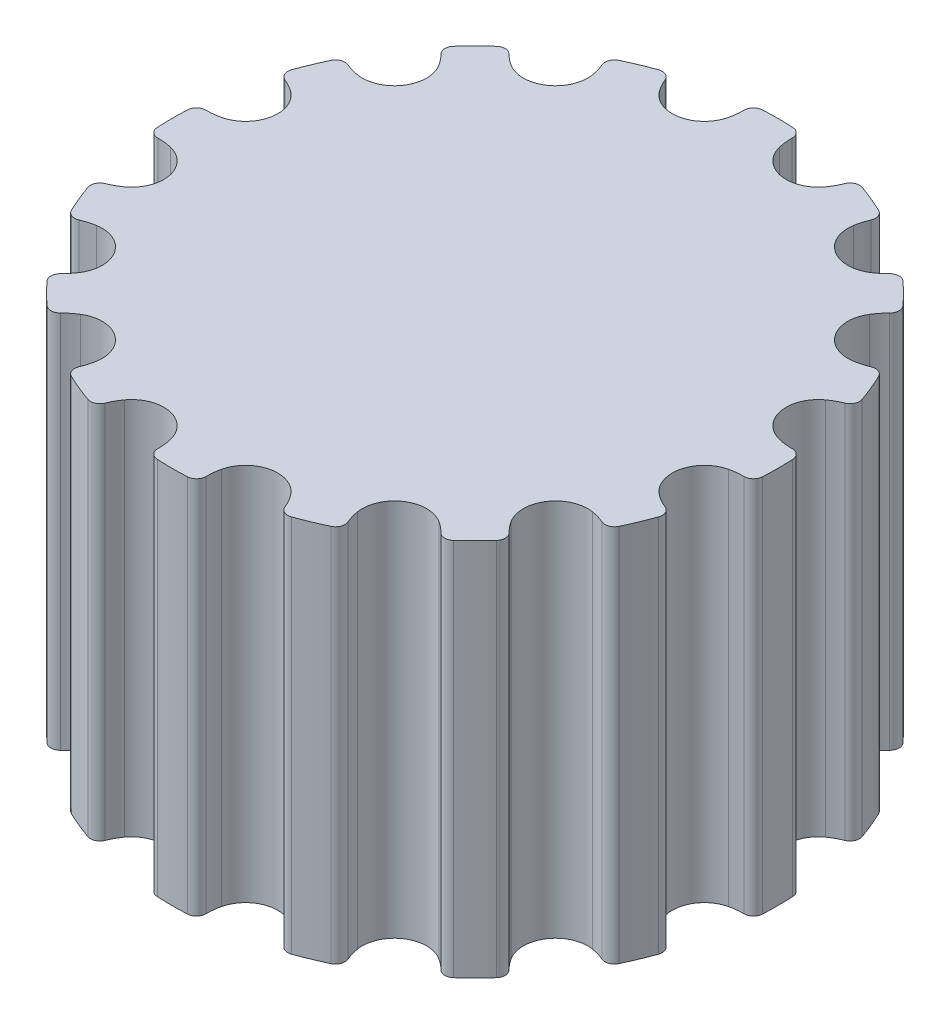
from build123d import *

# Parameters (mm, degrees)
BOSS_EXTRUDE1_DEPTH = 10


with BuildPart() as part:
    # Sketch1 → Boss-Extrude1 (new body)
    with BuildSketch(Plane(origin=(0, 0, 0), x_dir=(1, 0, 0), z_dir=(0, 1, 0))):
        with BuildLine():
            ThreePointArc((-0.399150386, 7.990036231), (0, 8), (0.399150386, 7.990036231))
            ThreePointArc((0.399150386, 7.990036231), (0.569055955, 7.911338515), (0.636650592, 7.736718362))
            ThreePointArc((0.636650592, 7.736718362), (0.645310767, 7.551140962), (0.676545739, 7.368006184))
            ThreePointArc((0.676545739, 7.368006184), (0.913327757, 6.950762578), (1.338319609, 6.728187024))
            ThreePointArc((1.338319609, 6.728187024), (1.816136859, 6.771182682), (2.194567135, 7.066052955))
            ThreePointArc((2.194567135, 7.066052955), (2.293507132, 7.223294321), (2.372525487, 7.391431377))
            ThreePointArc((2.372525487, 7.391431377), (2.501799028, 7.526892015), (2.688887618, 7.534579177))
            ThreePointArc((2.688887618, 7.534579177), (3.061467459, 7.39103626), (3.426421361, 7.229082698))
            ThreePointArc((3.426421361, 7.229082698), (3.553277327, 7.091355443), (3.548902389, 6.90416011))
            ThreePointArc((3.548902389, 6.90416011), (3.485885951, 6.729394842), (3.444660657, 6.548247264))
            ThreePointArc((3.444660657, 6.548247264), (3.503746502, 6.07215188), (3.811211799, 5.70388154))
            ThreePointArc((3.811211799, 5.70388154), (4.269111103, 5.560751604), (4.731577057, 5.688357216))
            ThreePointArc((4.731577057, 5.688357216), (4.88315936, 5.795766599), (5.020506067, 5.920865969))
            ThreePointArc((5.020506067, 5.920865969), (5.191777788, 5.996544437), (5.367566856, 5.932050745))
            ThreePointArc((5.367566856, 5.932050745), (5.656854249, 5.656854249), (5.932050745, 5.367566856))
            ThreePointArc((5.932050745, 5.367566856), (5.996544437, 5.191777788), (5.920865969, 5.020506067))
            ThreePointArc((5.920865969, 5.020506067), (5.795766599, 4.88315936), (5.688357216, 4.731577057))
            ThreePointArc((5.688357216, 4.731577057), (5.560751604, 4.269111103), (5.70388154, 3.811211799))
            ThreePointArc((5.70388154, 3.811211799), (6.07215188, 3.503746502), (6.548247264, 3.444660657))
            ThreePointArc((6.548247264, 3.444660657), (6.729394842, 3.485885951), (6.90416011, 3.548902389))
            ThreePointArc((6.90416011, 3.548902389), (7.091355443, 3.553277327), (7.229082698, 3.426421361))
            ThreePointArc((7.229082698, 3.426421361), (7.39103626, 3.061467459), (7.534579177, 2.688887618))
            ThreePointArc((7.534579177, 2.688887618), (7.526892015, 2.501799028), (7.391431377, 2.372525487))
            ThreePointArc((7.391431377, 2.372525487), (7.223294321, 2.293507132), (7.066052955, 2.194567135))
            ThreePointArc((7.066052955, 2.194567135), (6.771182682, 1.816136859), (6.728187024, 1.338319609))
            ThreePointArc((6.728187024, 1.338319609), (6.950762578, 0.913327757), (7.368006184, 0.676545739))
            ThreePointArc((7.368006184, 0.676545739), (7.551140962, 0.645310767), (7.736718362, 0.636650592))
            ThreePointArc((7.736718362, 0.636650592), (7.911338515, 0.569055955), (7.990036231, 0.399150386))
            ThreePointArc((7.990036231, 0.399150386), (8, 0), (7.990036231, -0.399150386))
            ThreePointArc((7.990036231, -0.399150386), (7.911338515, -0.569055955), (7.736718362, -0.636650592))
            ThreePointArc((7.736718362, -0.636650592), (7.551140962, -0.645310767), (7.368006184, -0.676545739))
            ThreePointArc((7.368006184, -0.676545739), (6.950762578, -0.913327757), (6.728187024, -1.338319609))
            ThreePointArc((6.728187024, -1.338319609), (6.771182682, -1.816136859), (7.066052955, -2.194567135))
            ThreePointArc((7.066052955, -2.194567135), (7.223294321, -2.293507132), (7.391431377, -2.372525487))
            ThreePointArc((7.391431377, -2.372525487), (7.526892015, -2.501799028), (7.534579177, -2.688887618))
            ThreePointArc((7.534579177, -2.688887618), (7.39103626, -3.061467459), (7.229082698, -3.426421361))
            ThreePointArc((7.229082698, -3.426421361), (7.091355443, -3.553277327), (6.90416011, -3.548902389))
            ThreePointArc((6.90416011, -3.548902389), (6.729394842, -3.485885951), (6.548247264, -3.444660657))
            ThreePointArc((6.548247264, -3.444660657), (6.07215188, -3.503746502), (5.70388154, -3.811211799))
            ThreePointArc((5.70388154, -3.811211799), (5.560751604, -4.269111103), (5.688357216, -4.731577057))
            ThreePointArc((5.688357216, -4.731577057), (5.795766599, -4.88315936), (5.920865969, -5.020506067))
            ThreePointArc((5.920865969, -5.020506067), (5.996544437, -5.191777788), (5.932050745, -5.367566856))
            ThreePointArc((5.932050745, -5.367566856), (5.656854249, -5.656854249), (5.367566856, -5.932050745))
            ThreePointArc((5.367566856, -5.932050745), (5.191777788, -5.996544437), (5.020506067, -5.920865969))
            ThreePointArc((5.020506067, -5.920865969), (4.88315936, -5.795766599), (4.731577057, -5.688357216))
            ThreePointArc((4.731577057, -5.688357216), (4.269111103, -5.560751604), (3.811211799, -5.70388154))
            ThreePointArc((3.811211799, -5.70388154), (3.503746502, -6.07215188), (3.444660657, -6.548247264))
            ThreePointArc((3.444660657, -6.548247264), (3.485885951, -6.729394842), (3.548902389, -6.90416011))
            ThreePointArc((3.548902389, -6.90416011), (3.553277327, -7.091355443), (3.426421361, -7.229082698))
            ThreePointArc((3.426421361, -7.229082698), (3.061467459, -7.39103626), (2.688887618, -7.534579177))
            ThreePointArc((2.688887618, -7.534579177), (2.501799028, -7.526892015), (2.372525487, -7.391431377))
            ThreePointArc((2.372525487, -7.391431377), (2.293507132, -7.223294321), (2.194567135, -7.066052955))
            ThreePointArc((2.194567135, -7.066052955), (1.816136859, -6.771182682), (1.338319609, -6.728187024))
            ThreePointArc((1.338319609, -6.728187024), (0.913327757, -6.950762578), (0.676545739, -7.368006184))
            ThreePointArc((0.676545739, -7.368006184), (0.645310767, -7.551140962), (0.636650592, -7.736718362))
            ThreePointArc((0.636650592, -7.736718362), (0.569055955, -7.911338515), (0.399150386, -7.990036231))
            ThreePointArc((0.399150386, -7.990036231), (0, -8), (-0.399150386, -7.990036231))
            ThreePointArc((-0.399150386, -7.990036231), (-0.569055955, -7.911338515), (-0.636650592, -7.736718362))
            ThreePointArc((-0.636650592, -7.736718362), (-0.645310767, -7.551140962), (-0.676545739, -7.368006184))
            ThreePointArc((-0.676545739, -7.368006184), (-0.913327757, -6.950762578), (-1.338319609, -6.728187024))
            ThreePointArc((-1.338319609, -6.728187024), (-1.816136859, -6.771182682), (-2.194567135, -7.066052955))
            ThreePointArc((-2.194567135, -7.066052955), (-2.293507132, -7.223294321), (-2.372525487, -7.391431377))
            ThreePointArc((-2.372525487, -7.391431377), (-2.501799028, -7.526892015), (-2.688887618, -7.534579177))
            ThreePointArc((-2.688887618, -7.534579177), (-3.061467459, -7.39103626), (-3.426421361, -7.229082698))
            ThreePointArc((-3.426421361, -7.229082698), (-3.553277327, -7.091355443), (-3.548902389, -6.90416011))
            ThreePointArc((-3.548902389, -6.90416011), (-3.485885951, -6.729394842), (-3.444660657, -6.548247264))
            ThreePointArc((-3.444660657, -6.548247264), (-3.503746502, -6.07215188), (-3.811211799, -5.70388154))
            ThreePointArc((-3.811211799, -5.70388154), (-4.269111103, -5.560751604), (-4.731577057, -5.688357216))
            ThreePointArc((-4.731577057, -5.688357216), (-4.88315936, -5.795766599), (-5.020506067, -5.920865969))
            ThreePointArc((-5.020506067, -5.920865969), (-5.191777788, -5.996544437), (-5.367566856, -5.932050745))
            ThreePointArc((-5.367566856, -5.932050745), (-5.656854249, -5.656854249), (-5.932050745, -5.367566856))
            ThreePointArc((-5.932050745, -5.367566856), (-5.996544437, -5.191777788), (-5.920865969, -5.020506067))
            ThreePointArc((-5.920865969, -5.020506067), (-5.795766599, -4.88315936), (-5.688357216, -4.731577057))
            ThreePointArc((-5.688357216, -4.731577057), (-5.560751604, -4.269111103), (-5.70388154, -3.811211799))
            ThreePointArc((-5.70388154, -3.811211799), (-6.07215188, -3.503746502), (-6.548247264, -3.444660657))
            ThreePointArc((-6.548247264, -3.444660657), (-6.729394842, -3.485885951), (-6.90416011, -3.548902389))
            ThreePointArc((-6.90416011, -3.548902389), (-7.091355443, -3.553277327), (-7.229082698, -3.426421361))
            ThreePointArc((-7.229082698, -3.426421361), (-7.39103626, -3.061467459), (-7.534579177, -2.688887618))
            ThreePointArc((-7.534579177, -2.688887618), (-7.526892015, -2.501799028), (-7.391431377, -2.372525487))
            ThreePointArc((-7.391431377, -2.372525487), (-7.223294321, -2.293507132), (-7.066052955, -2.194567135))
            ThreePointArc((-7.066052955, -2.194567135), (-6.771182682, -1.816136859), (-6.728187024, -1.338319609))
            ThreePointArc((-6.728187024, -1.338319609), (-6.950762578, -0.913327757), (-7.368006184, -0.676545739))
            ThreePointArc((-7.368006184, -0.676545739), (-7.551140962, -0.645310767), (-7.736718362, -0.636650592))
            ThreePointArc((-7.736718362, -0.636650592), (-7.911338515, -0.569055955), (-7.990036231, -0.399150386))
            ThreePointArc((-7.990036231, -0.399150386), (-8, 0), (-7.990036231, 0.399150386))
            ThreePointArc((-7.990036231, 0.399150386), (-7.911338515, 0.569055955), (-7.736718362, 0.636650592))
            ThreePointArc((-7.736718362, 0.636650592), (-7.551140962, 0.645310767), (-7.368006184, 0.676545739))
            ThreePointArc((-7.368006184, 0.676545739), (-6.950762578, 0.913327757), (-6.728187024, 1.338319609))
            ThreePointArc((-6.728187024, 1.338319609), (-6.771182682, 1.816136859), (-7.066052955, 2.194567135))
            ThreePointArc((-7.066052955, 2.194567135), (-7.223294321, 2.293507132), (-7.391431377, 2.372525487))
            ThreePointArc((-7.391431377, 2.372525487), (-7.526892015, 2.501799028), (-7.534579177, 2.688887618))
            ThreePointArc((-7.534579177, 2.688887618), (-7.39103626, 3.061467459), (-7.229082698, 3.426421361))
            ThreePointArc((-7.229082698, 3.426421361), (-7.091355443, 3.553277327), (-6.90416011, 3.548902389))
            ThreePointArc((-6.90416011, 3.548902389), (-6.729394842, 3.485885951), (-6.548247264, 3.444660657))
            ThreePointArc((-6.548247264, 3.444660657), (-6.07215188, 3.503746502), (-5.70388154, 3.811211799))
            ThreePointArc((-5.70388154, 3.811211799), (-5.560751604, 4.269111103), (-5.688357216, 4.731577057))
            ThreePointArc((-5.688357216, 4.731577057), (-5.795766599, 4.88315936), (-5.920865969, 5.020506067))
            ThreePointArc((-5.920865969, 5.020506067), (-5.996544437, 5.191777788), (-5.932050745, 5.367566856))
            ThreePointArc((-5.932050745, 5.367566856), (-5.656854249, 5.656854249), (-5.367566856, 5.932050745))
            ThreePointArc((-5.367566856, 5.932050745), (-5.191777788, 5.996544437), (-5.020506067, 5.920865969))
            ThreePointArc((-5.020506067, 5.920865969), (-4.88315936, 5.795766599), (-4.731577057, 5.688357216))
            ThreePointArc((-4.731577057, 5.688357216), (-4.269111103, 5.560751604), (-3.811211799, 5.70388154))
            ThreePointArc((-3.811211799, 5.70388154), (-3.503746502, 6.07215188), (-3.444660657, 6.548247264))
            ThreePointArc((-3.444660657, 6.548247264), (-3.485885951, 6.729394842), (-3.548902389, 6.90416011))
            ThreePointArc((-3.548902389, 6.90416011), (-3.553277327, 7.091355443), (-3.426421361, 7.229082698))
            ThreePointArc((-3.426421361, 7.229082698), (-3.061467459, 7.39103626), (-2.688887618, 7.534579177))
            ThreePointArc((-2.688887618, 7.534579177), (-2.501799028, 7.526892015), (-2.372525487, 7.391431377))
            ThreePointArc((-2.372525487, 7.391431377), (-2.293507132, 7.223294321), (-2.194567135, 7.066052955))
            ThreePointArc((-2.194567135, 7.066052955), (-1.816136859, 6.771182682), (-1.338319609, 6.728187024))
            ThreePointArc((-1.338319609, 6.728187024), (-0.913327757, 6.950762578), (-0.676545739, 7.368006184))
            ThreePointArc((-0.676545739, 7.368006184), (-0.645310767, 7.551140962), (-0.636650592, 7.736718362))
            ThreePointArc((-0.636650592, 7.736718362), (-0.569055955, 7.911338515), (-0.399150386, 7.990036231))
        make_face()
    extrude(amount=BOSS_EXTRUDE1_DEPTH)


solid = part.part
